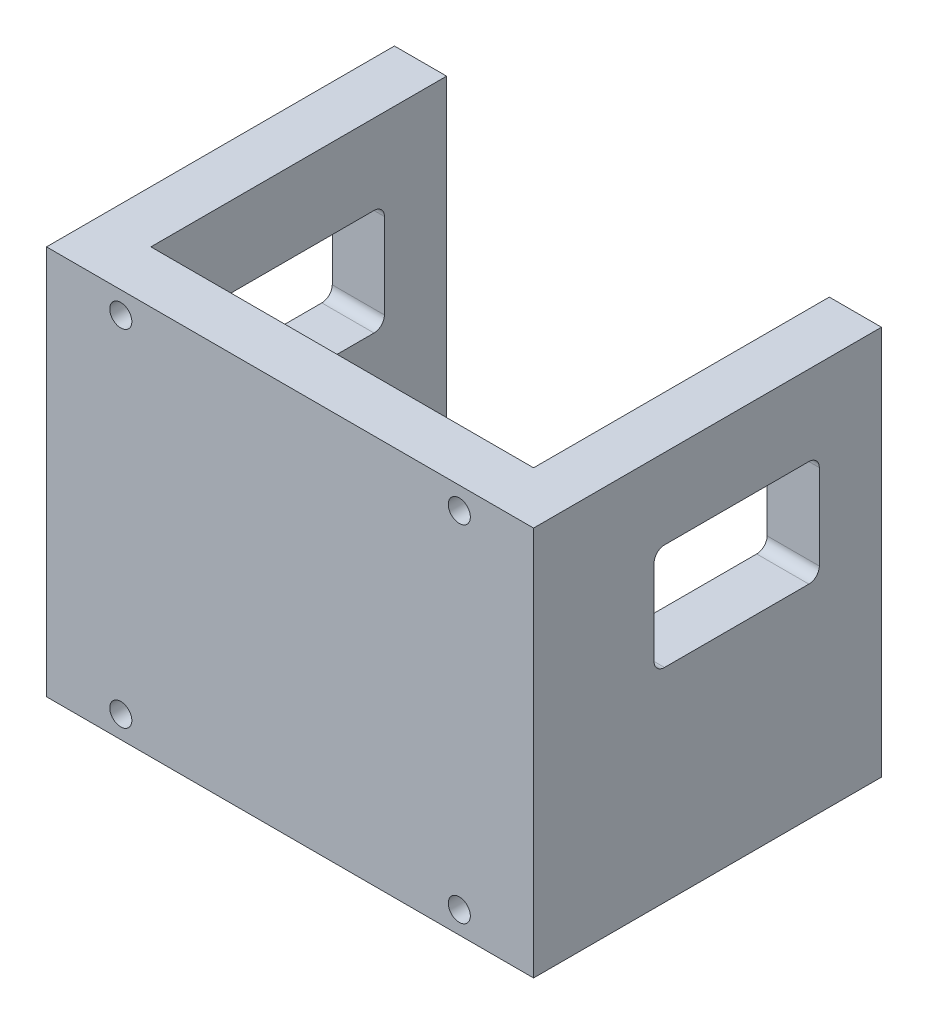
from build123d import *

# Parameters (mm, degrees)
ESQUISSE1_W               = 140
ESQUISSE1_H               = 112
BOSS_EXTRU_1_DEPTH        = 100
ESQUISSE2_W               = 110
ESQUISSE2_H               = 85
ENL_V_MAT_EXTRU_1_DEPTH   = 113
ESQUISSE3_W               = 47.5
ESQUISSE3_H               = 30.5
ENL_V_MAT_EXTRU_2_DEPTH   = 141
ESQUISSE4_R               = 3.175
ENL_V_MAT_EXTRU_3_DEPTH   = 16
SYM_TRIE2_COPY_1_SKETCH_R = 3.175
SYM_TRIE2_COPY_1_DEPTH    = 16
CONG_1_R                  = 3


with BuildPart() as part:
    # Esquisse1 → Boss.-Extru.1 (new body)
    with BuildSketch(Plane.XY):
        with Locations((-39.52963138, -51.586067687)):
            Rectangle(ESQUISSE1_W, ESQUISSE1_H)
    extrude(amount=BOSS_EXTRU_1_DEPTH)

    # Esquisse2 → Enlèv. mat.-Extru.1 (cut, through all)
    with BuildSketch(Plane(origin=(0, 4.413932313, 0), x_dir=(1, 0, 0), z_dir=(0, 1, 0))):
        with Locations((-39.52963138, -42.5)):
            Rectangle(ESQUISSE2_W, ESQUISSE2_H)
    extrude(amount=-ENL_V_MAT_EXTRU_1_DEPTH, mode=Mode.SUBTRACT)

    # Esquisse3 → Enlèv. mat.-Extru.2 (cut, through all)
    with BuildSketch(Plane.ZY.offset(109.52963138)):
        with Locations((41.617518417, -33.84820443)):
            Rectangle(ESQUISSE3_W, ESQUISSE3_H)
    extrude(amount=-ENL_V_MAT_EXTRU_2_DEPTH, mode=Mode.SUBTRACT)

    # Esquisse4 → Enlèv. mat.-Extru.3 (cut, through all)
    with BuildSketch(Plane(origin=(0, 0, 85), x_dir=(-1, 0, 0), z_dir=(0, 0, -1))):
        with Locations((-9.12036862, -1.936067687)):
            Circle(ESQUISSE4_R)
    enl_v_mat_extru_3 = extrude(amount=-ENL_V_MAT_EXTRU_3_DEPTH, mode=Mode.SUBTRACT)

    # Symétrie1: Enlèv. mat.-Extru.3 across plane
    add(enl_v_mat_extru_3.mirror(Plane(origin=(-39.52963138, 0, 0), x_dir=(0, 0, 1), z_dir=(1, 0, 0))), mode=Mode.SUBTRACT)

    # Symétrie2: Enlèv. mat.-Extru.3 across plane
    add(enl_v_mat_extru_3.mirror(Plane(origin=(0, -51.586067687, 0), x_dir=(0, 0, 1), z_dir=(0, -1, 0))), mode=Mode.SUBTRACT)

    # Symétrie2 copy 1 sketch → Symétrie2 copy 1 (cut, through all)
    with BuildSketch(Plane(origin=(-79.05926276, -103.172135375, 85), x_dir=(1, 0, 0), z_dir=(0, 0, -1))):
        with Locations((-9.12036862, -1.936067687)):
            Circle(SYM_TRIE2_COPY_1_SKETCH_R)
    extrude(amount=-SYM_TRIE2_COPY_1_DEPTH, mode=Mode.SUBTRACT)

    # Congé1
    cong_1_edges = [part.edges().sort_by_distance(p)[0] for p in [
        (-102.02963138, -49.09820443, 17.867518417),
        (-102.02963138, -18.59820443, 17.867518417),
        (-102.02963138, -18.59820443, 65.367518417),
        (-102.02963138, -49.09820443, 65.367518417),
        (22.97036862, -49.09820443, 17.867518417),
        (22.97036862, -18.59820443, 17.867518417),
        (22.97036862, -18.59820443, 65.367518417),
        (22.97036862, -49.09820443, 65.367518417),
    ]]
    fillet(cong_1_edges, radius=CONG_1_R)


solid = part.part
